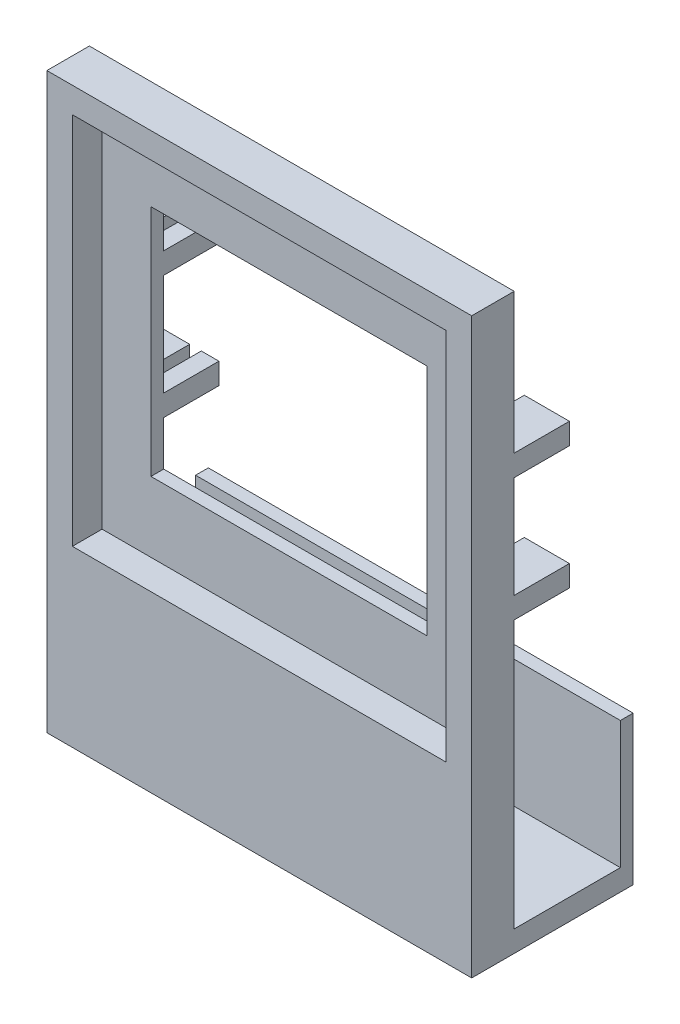
from build123d import *

# Parameters (mm, degrees)
SKETCH_1_W          = 100
SKETCH_1_H          = 100
EXTRUDE_1_DEPTH     = 10
SKETCH_2_W          = 65
SKETCH_2_H          = 55
CUT_EXTRUDE_1_DEPTH = 11
SKETCH_3_W          = 88
SKETCH_3_H          = 88
CUT_EXTRUDE_2_DEPTH = 7
SKETCH_4_W          = 100
SKETCH_4_H          = 38
EXTRUDE_2_DEPTH     = 35
SKETCH_8_W          = 100
SKETCH_8_H          = 25
CUT_EXTRUDE_3_DEPTH = 30
SKETCH_9_W          = 17.5
SKETCH_9_H          = 5
EXTRUDE_3_DEPTH     = 13
SKETCH_10_W         = 2.733389199
SKETCH_10_H         = 5
CUT_EXTRUDE_5_DEPTH = 12
SKETCH_11_W         = 32.468839848
SKETCH_11_H         = 16.671988928
CUT_EXTRUDE_6_DEPTH = 12


with BuildPart() as part:
    # 草图1 → 凸台-拉伸1 (new body)
    with BuildSketch(Plane.XY):
        Rectangle(SKETCH_1_W, SKETCH_1_H)
    extrude(amount=EXTRUDE_1_DEPTH)

    # 草图2 → 切除-拉伸1 (cut, through all)
    with BuildSketch(Plane.XY.offset(10)):
        Rectangle(SKETCH_2_W, SKETCH_2_H)
    extrude(amount=-CUT_EXTRUDE_1_DEPTH, mode=Mode.SUBTRACT)

    # 草图3 → 切除-拉伸2 (cut)
    with BuildSketch(Plane.XY.offset(10)):
        Rectangle(SKETCH_3_W, SKETCH_3_H)
    extrude(amount=-CUT_EXTRUDE_2_DEPTH, mode=Mode.SUBTRACT)

    # 草图4 → 凸台-拉伸2 (add)
    with BuildSketch(Plane.XZ.offset(50)):
        with Locations((0, -9)):
            Rectangle(SKETCH_4_W, SKETCH_4_H)
    extrude(amount=EXTRUDE_2_DEPTH)

    # 草图8 → 切除-拉伸3 (cut)
    with BuildSketch(Plane(origin=(0, -50, 0), x_dir=(1, 0, 0), z_dir=(0, 1, 0))):
        with Locations((0, 12.5)):
            Rectangle(SKETCH_8_W, SKETCH_8_H)
    extrude(amount=-CUT_EXTRUDE_3_DEPTH, mode=Mode.SUBTRACT)

    # 草图9 → 凸台-拉伸3 (add)
    with BuildSketch(Plane(origin=(0, 0, 0), x_dir=(-1, 0, 0), z_dir=(0, 0, -1))):
        with Locations((-41.25, 14.5)):
            Rectangle(SKETCH_9_W, SKETCH_9_H)
        with Locations((-41.25, -14.5)):
            Rectangle(SKETCH_9_W, SKETCH_9_H)
        with Locations((41.25, 14.5)):
            Rectangle(SKETCH_9_W, SKETCH_9_H)
        with Locations((41.25, -14.5)):
            Rectangle(SKETCH_9_W, SKETCH_9_H)
    extrude(amount=EXTRUDE_3_DEPTH)

    # 草图10 → 切除-拉伸5 (cut)
    with BuildSketch(Plane(origin=(0, 0, -13), x_dir=(-1, 0, 0), z_dir=(0, 0, -1))):
        with Locations((-38.018129079, 14.5)):
            Rectangle(SKETCH_10_W, SKETCH_10_H)
        with Locations((-38.018129079, -14.5)):
            Rectangle(SKETCH_10_W, SKETCH_10_H)
        with Locations((38.018129079, -14.5)):
            Rectangle(SKETCH_10_W, SKETCH_10_H)
        with Locations((38.018129079, 14.5)):
            Rectangle(SKETCH_10_W, SKETCH_10_H)
    extrude(amount=-CUT_EXTRUDE_5_DEPTH, mode=Mode.SUBTRACT)

    # 草图11 → 切除-拉伸6 (cut)
    with BuildSketch(Plane.XZ.offset(85)):
        with Locations((0, -12.262013559)):
            Rectangle(SKETCH_11_W, SKETCH_11_H)
    extrude(amount=-CUT_EXTRUDE_6_DEPTH, mode=Mode.SUBTRACT)


solid = part.part
